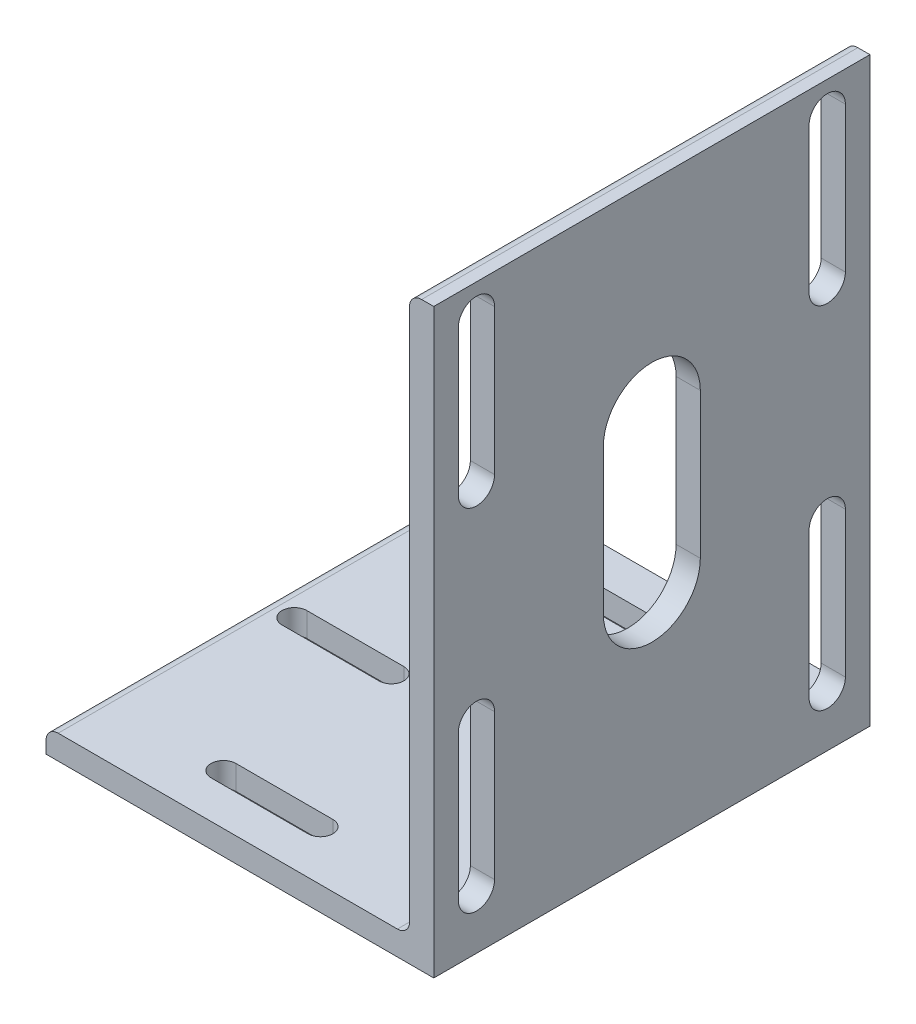
from build123d import *

# Parameters (mm, degrees)
BOSS_EXTRUDE1_DEPTH = 152.4
CUT_EXTRUDE1_DEPTH  = 239.273120599
CUT_EXTRUDE2_DEPTH  = 218.110576665


with BuildPart() as part:
    # Sketch2 → Boss-Extrude1 (new, symmetric)
    with BuildSketch(Plane.XY):
        with BuildLine():
            Line((-50.8, 0), (50.8, 0))
            Line((50.8, 0), (50.8, 152.4))
            Line((50.8, 152.4), (47.625, 152.4))
            ThreePointArc((47.625, 152.4), (45.37993597, 151.47006403), (44.45, 149.225))
            Line((44.45, 149.225), (44.45, 9.525))
            ThreePointArc((44.45, 9.525), (43.52006403, 7.27993597), (41.275, 6.35))
            Line((41.275, 6.35), (-47.625, 6.35))
            ThreePointArc((-47.625, 6.35), (-49.87006403, 5.42006403), (-50.8, 3.175))
            Line((-50.8, 3.175), (-50.8, 0))
        make_face()
    extrude(amount=BOSS_EXTRUDE1_DEPTH, both=True)

    # SurfaceCut1
    split(bisect_by=Plane(origin=(0, 0, -38.1), x_dir=(-1, 0, 0), z_dir=(0, 0, -1)), keep=Keep.TOP)

    # Sketch3 → Cut-Extrude1 (cut, through all)
    with BuildSketch(Plane(origin=(50.8, 0, 0), x_dir=(0, 0, -1), z_dir=(1, 0, 0))):
        with BuildLine():
            Line((145.961940777, 144.386940777), (145.961940777, 106.286940777))
            ThreePointArc((145.961940777, 106.286940777), (141.211940777, 101.536940777), (136.461940777, 106.286940777))
            Line((136.461940777, 106.286940777), (136.461940777, 144.386940777))
            ThreePointArc((136.461940777, 144.386940777), (141.211940777, 149.136940777), (145.961940777, 144.386940777))
        make_face()
        with BuildLine():
            Line((145.961940777, 52.463059223), (145.961940777, 14.363059223))
            ThreePointArc((145.961940777, 14.363059223), (141.211940777, 9.613059223), (136.461940777, 14.363059223))
            Line((136.461940777, 14.363059223), (136.461940777, 52.463059223))
            ThreePointArc((136.461940777, 52.463059223), (141.211940777, 57.213059223), (145.961940777, 52.463059223))
        make_face()
        with BuildLine():
            Line((44.538059223, 52.463059223), (44.538059223, 14.363059223))
            ThreePointArc((44.538059223, 14.363059223), (49.288059223, 9.613059223), (54.038059223, 14.363059223))
            Line((54.038059223, 14.363059223), (54.038059223, 52.463059223))
            ThreePointArc((54.038059223, 52.463059223), (49.288059223, 57.213059223), (44.538059223, 52.463059223))
        make_face()
        with BuildLine():
            Line((44.538059223, 144.386940777), (44.538059223, 106.286940777))
            ThreePointArc((44.538059223, 106.286940777), (49.288059223, 101.536940777), (54.038059223, 106.286940777))
            Line((54.038059223, 106.286940777), (54.038059223, 144.386940777))
            ThreePointArc((54.038059223, 144.386940777), (49.288059223, 149.136940777), (44.538059223, 144.386940777))
        make_face()
        with BuildLine():
            Line((107.95, 98.425), (107.95, 60.325))
            ThreePointArc((107.95, 60.325), (95.25, 47.625), (82.55, 60.325))
            Line((82.55, 60.325), (82.55, 98.425))
            ThreePointArc((82.55, 98.425), (95.25, 111.125), (107.95, 98.425))
        make_face()
    extrude(amount=-CUT_EXTRUDE1_DEPTH, mode=Mode.SUBTRACT)

    # Sketch4 → Cut-Extrude2 (cut, through all)
    with BuildSketch(Plane(origin=(0, 6.35, 0), x_dir=(1, 0, 0), z_dir=(0, 1, 0))):
        with BuildLine():
            Line((-42.8625, 98.5139), (-17.4625, 98.5139))
            ThreePointArc((-17.4625, 98.5139), (-14.1986, 95.25), (-17.4625, 91.9861))
            Line((-17.4625, 91.9861), (-42.8625, 91.9861))
            ThreePointArc((-42.8625, 91.9861), (-46.1264, 95.25), (-42.8625, 98.5139))
        make_face()
        with BuildLine():
            Line((7.9375, 98.5139), (33.3375, 98.5139))
            ThreePointArc((33.3375, 98.5139), (36.6014, 95.25), (33.3375, 91.9861))
            Line((33.3375, 91.9861), (7.9375, 91.9861))
            ThreePointArc((7.9375, 91.9861), (4.6736, 95.25), (7.9375, 98.5139))
        make_face()
        with BuildLine():
            Line((-17.4625, 142.507990512), (7.9375, 142.507990512))
            ThreePointArc((7.9375, 142.507990512), (11.2014, 139.244090512), (7.9375, 135.980190512))
            Line((7.9375, 135.980190512), (-17.4625, 135.980190512))
            ThreePointArc((-17.4625, 135.980190512), (-20.7264, 139.244090512), (-17.4625, 142.507990512))
        make_face()
        with BuildLine():
            Line((-17.4625, 47.992009488), (7.9375, 47.992009488))
            ThreePointArc((7.9375, 47.992009488), (11.2014, 51.255909488), (7.9375, 54.519809488))
            Line((7.9375, 54.519809488), (-17.4625, 54.519809488))
            ThreePointArc((-17.4625, 54.519809488), (-20.7264, 51.255909488), (-17.4625, 47.992009488))
        make_face()
    extrude(amount=-CUT_EXTRUDE2_DEPTH, mode=Mode.SUBTRACT)


solid = part.part
